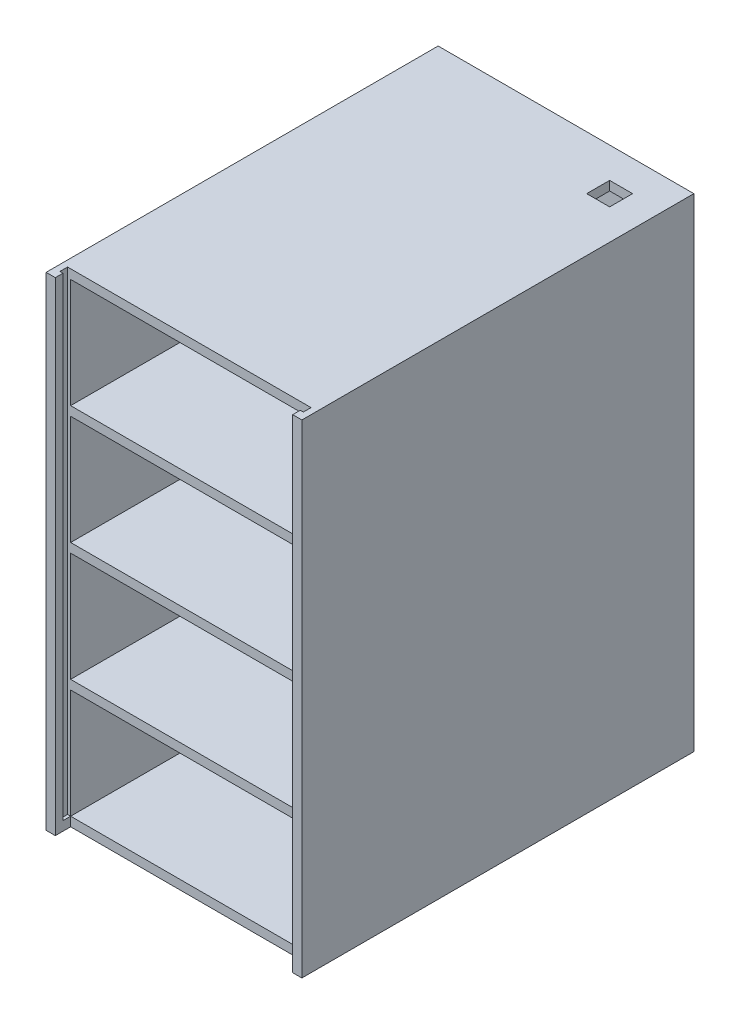
from build123d import *

# Parameters (mm, degrees)
SKETCH1_W           = 83.5
SKETCH1_H           = 157.8
SKETCH1_W_2         = 77.5
SKETCH1_H_2         = 35.7
BOSS_EXTRUDE1_DEPTH = 123
SKETCH1_3_W         = 77.5
SKETCH1_3_H         = 35.7
BOSS_EXTRUDE2_DEPTH = 3
SKETCH2_W           = 77.5
SKETCH2_H           = 27
CUT_EXTRUDE1_DEPTH  = 100
SKETCH4_W           = 3
SKETCH4_H           = 10
BOSS_EXTRUDE3_DEPTH = 10
SKETCH5_W           = 3
SKETCH5_H           = 10
BOSS_EXTRUDE4_DEPTH = 10
SKETCH7_W           = 3
SKETCH7_H           = 157.8
BOSS_EXTRUDE5_DEPTH = 5
SKETCH8_W           = 1
SKETCH8_H           = 2.5
CUT_EXTRUDE2_DEPTH  = 154.8
SKETCH9_W           = 7.5
SKETCH9_H           = 7.5
CUT_EXTRUDE3_DEPTH  = 10


with BuildPart() as part:
    # Sketch1 → Boss-Extrude1 (new body)
    with BuildSketch(Plane.XY):
        with Locations((41.75, 78.9)):
            Rectangle(SKETCH1_W, SKETCH1_H)
        with Locations((41.75, 20.85)):
            Rectangle(SKETCH1_W_2, SKETCH1_H_2, mode=Mode.SUBTRACT)
        with Locations((41.75, 59.55)):
            Rectangle(SKETCH1_W_2, SKETCH1_H_2, mode=Mode.SUBTRACT)
        with Locations((41.75, 98.25)):
            Rectangle(SKETCH1_W_2, SKETCH1_H_2, mode=Mode.SUBTRACT)
        with Locations((41.75, 136.95)):
            Rectangle(SKETCH1_W_2, SKETCH1_H_2, mode=Mode.SUBTRACT)
    extrude(amount=BOSS_EXTRUDE1_DEPTH)

    # Sketch1_3 → Boss-Extrude2 (add)
    with BuildSketch(Plane.XY):
        with Locations((41.75, 20.85)):
            Rectangle(SKETCH1_3_W, SKETCH1_3_H)
        with Locations((41.75, 59.55)):
            Rectangle(SKETCH1_3_W, SKETCH1_3_H)
        with Locations((41.75, 98.25)):
            Rectangle(SKETCH1_3_W, SKETCH1_3_H)
        with Locations((41.75, 136.95)):
            Rectangle(SKETCH1_3_W, SKETCH1_3_H)
    extrude(amount=BOSS_EXTRUDE2_DEPTH)

    # Sketch2 → Cut-Extrude1 (cut)
    with BuildSketch(Plane(origin=(0, 119.1, 0), x_dir=(1, 0, 0), z_dir=(0, 1, 0))):
        with Locations((41.75, -16.5)):
            Rectangle(SKETCH2_W, SKETCH2_H)
    extrude(amount=-CUT_EXTRUDE1_DEPTH, mode=Mode.SUBTRACT)

    # Sketch4 → Boss-Extrude3 (add)
    with BuildSketch(Plane(origin=(3, 0, 0), x_dir=(0, 0, -1), z_dir=(1, 0, 0))):
        with Locations((-31.5, 85.4)):
            Rectangle(SKETCH4_W, SKETCH4_H)
        with Locations((-31.5, 124.1)):
            Rectangle(SKETCH4_W, SKETCH4_H)
        with Locations((-31.5, 46.7)):
            Rectangle(SKETCH4_W, SKETCH4_H)
        with Locations((-31.5, 8)):
            Rectangle(SKETCH4_W, SKETCH4_H)
    extrude(amount=BOSS_EXTRUDE3_DEPTH)

    # Sketch5 → Boss-Extrude4 (add)
    with BuildSketch(Plane.ZY.offset(-80.5)):
        with Locations((31.5, 85.4)):
            Rectangle(SKETCH5_W, SKETCH5_H)
        with Locations((31.5, 124.1)):
            Rectangle(SKETCH5_W, SKETCH5_H)
        with Locations((31.5, 46.7)):
            Rectangle(SKETCH5_W, SKETCH5_H)
        with Locations((31.5, 8)):
            Rectangle(SKETCH5_W, SKETCH5_H)
    extrude(amount=BOSS_EXTRUDE4_DEPTH)

    # Sketch7 → Boss-Extrude5 (add)
    with BuildSketch(Plane.XY.offset(123)):
        with Locations((1.5, 78.9)):
            Rectangle(SKETCH7_W, SKETCH7_H)
        with Locations((82, 78.9)):
            Rectangle(SKETCH7_W, SKETCH7_H)
    extrude(amount=BOSS_EXTRUDE5_DEPTH)

    # Sketch8 → Cut-Extrude2 (cut)
    with BuildSketch(Plane(origin=(0, 157.8, 0), x_dir=(1, 0, 0), z_dir=(0, 1, 0))):
        with Locations((2.5, -124.25)):
            Rectangle(SKETCH8_W, SKETCH8_H)
        with Locations((81, -124.25)):
            Rectangle(SKETCH8_W, SKETCH8_H)
    extrude(amount=-CUT_EXTRUDE2_DEPTH, mode=Mode.SUBTRACT)

    # Sketch9 → Cut-Extrude3 (cut)
    with BuildSketch(Plane(origin=(0, 157.8, 0), x_dir=(1, 0, 0), z_dir=(0, 1, 0))):
        with Locations((69.75, -13.75)):
            Rectangle(SKETCH9_W, SKETCH9_H)
    extrude(amount=-CUT_EXTRUDE3_DEPTH, mode=Mode.SUBTRACT)


solid = part.part
